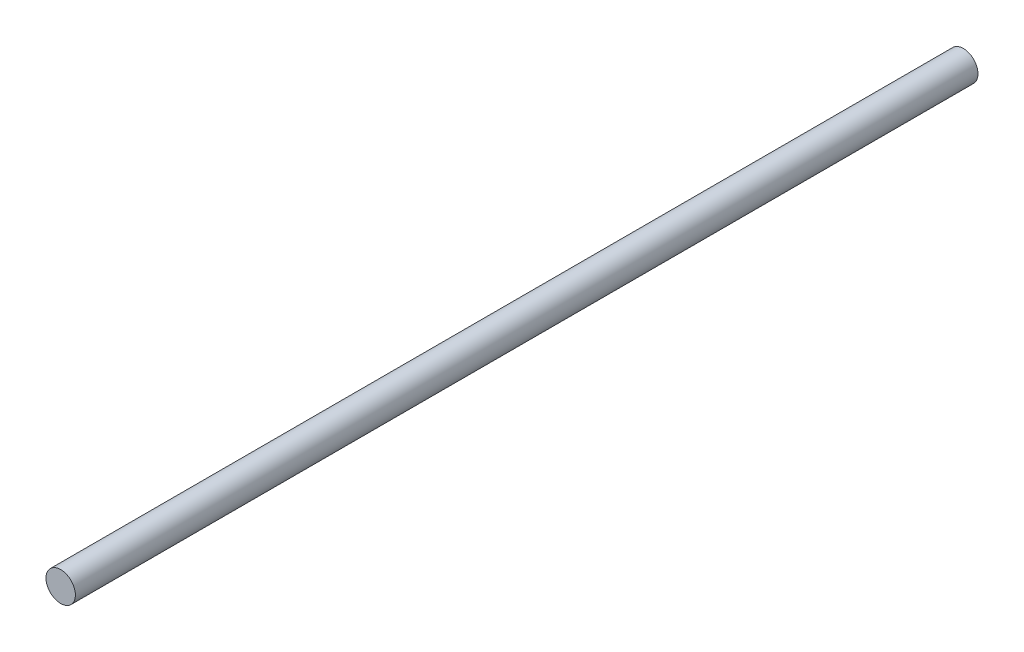
from build123d import *

# Parameters (mm, degrees)
SKETCH1_R           = 2.95
BOSS_EXTRUDE1_DEPTH = 181


with BuildPart() as part:
    # Sketch1 → Boss-Extrude1 (new body)
    with BuildSketch(Plane.XY):
        Circle(SKETCH1_R)
    extrude(amount=BOSS_EXTRUDE1_DEPTH)


solid = part.part
